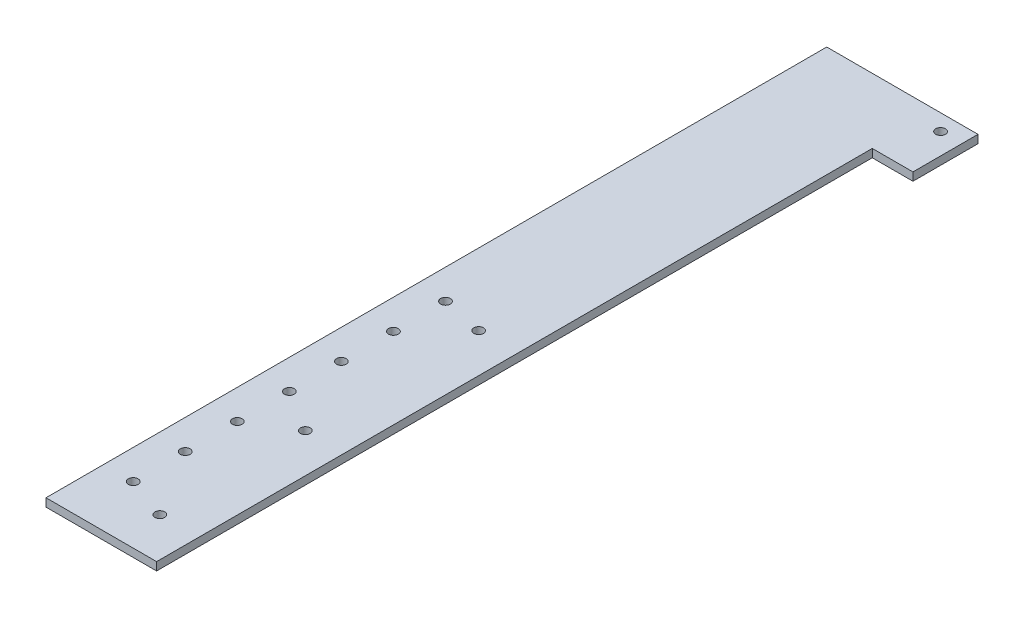
from build123d import *

# Parameters (mm, degrees)
SKETCH1_W                    = 25.4
SKETCH1_H                    = 25.4
SKETCH1_W_2                  = 15.875
SKETCH1_H_2                  = 279.4
BOSS_EXTRUDE1_DEPTH          = 3.175
F_25_0_1495_DIAMETER_HOLE2_D = 3.7973
SKETCH4_W                    = 304.8
SKETCH4_H                    = 3.175
BOSS_EXTRUDE2_DEPTH          = 17.78
SKETCH5_R                    = 0.127
CUT_EXTRUDE1_DEPTH           = 4.175
F_25_0_1495_DIAMETER_HOLE1_D = 3.7973


with BuildPart() as part:
    # Sketch1 → Boss-Extrude1 (new body)
    with BuildSketch(Plane(origin=(0, 0, 0), x_dir=(1, 0, 0), z_dir=(0, 1, 0))):
        with Locations((12.7, 292.1)):
            Rectangle(SKETCH1_W, SKETCH1_H)
        with Locations((33.3375, 292.1)):
            Rectangle(SKETCH1_W_2, SKETCH1_H)
        with Locations((12.7, 139.7)):
            Rectangle(SKETCH1_W, SKETCH1_H_2)
    extrude(amount=BOSS_EXTRUDE1_DEPTH)

    # #25 (0.1495) Diameter Hole2 (through all)
    with Locations(Plane(origin=(0, 3.175, 0), x_dir=(1, 0, 0), z_dir=(0, 1, 0))):
        with Locations((10.16, 16.51), (10.16, 73.308346978), (10.16, 140.97), (33.02, 298.45)):
            Hole(F_25_0_1495_DIAMETER_HOLE2_D / 2)

    # Sketch4 → Boss-Extrude2 (add)
    with BuildSketch(Plane.ZY):
        with Locations((-152.4, 1.5875)):
            Rectangle(SKETCH4_W, SKETCH4_H)
    extrude(amount=BOSS_EXTRUDE2_DEPTH)

    # Sketch5 → Cut-Extrude1 (cut, through all)
    with BuildSketch(Plane(origin=(0, 3.175, 0), x_dir=(1, 0, 0), z_dir=(0, 1, 0))):
        with Locations((-6.223, 42.799)):
            Circle(SKETCH5_R)
        with Locations((-6.223, 22.479)):
            Circle(SKETCH5_R)
        with Locations((-6.223, 63.119)):
            Circle(SKETCH5_R)
        with Locations((-6.223, 83.439)):
            Circle(SKETCH5_R)
        with Locations((-6.223, 103.759)):
            Circle(SKETCH5_R)
        with Locations((-6.223, 124.079)):
            Circle(SKETCH5_R)
        with Locations((-6.223, 144.399)):
            Circle(SKETCH5_R)
    extrude(amount=-CUT_EXTRUDE1_DEPTH, mode=Mode.SUBTRACT)

    # #25 (0.1495) Diameter Hole1 (through all)
    with Locations(Plane(origin=(0, 3.175, 0), x_dir=(1, 0, 0), z_dir=(0, 1, 0))):
        with Locations((-6.223, 42.799), (-6.223, 63.119), (-6.223, 83.439), (-6.223, 103.759), (-6.223, 124.079), (-6.223, 144.399), (-6.223, 22.479)):
            Hole(F_25_0_1495_DIAMETER_HOLE1_D / 2)


solid = part.part
